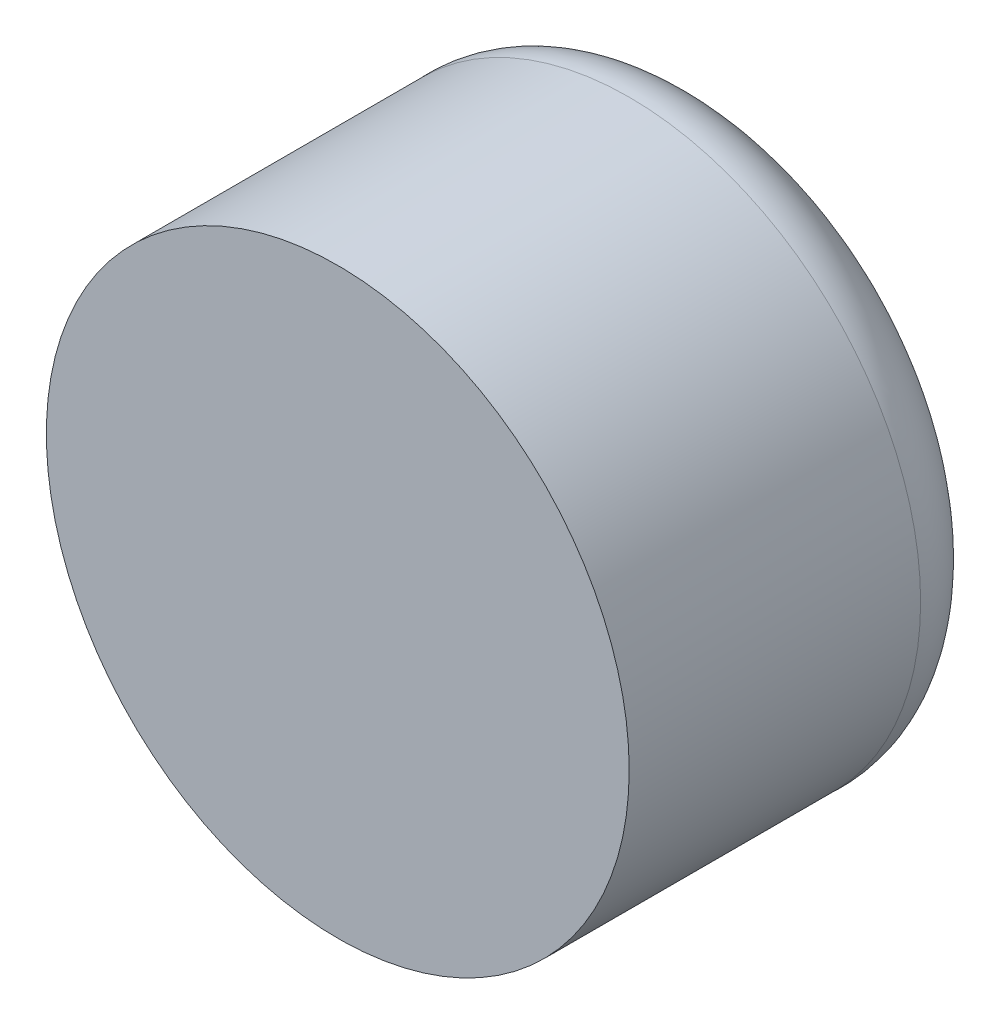
from build123d import *

# Parameters (mm, degrees)
SKETCH1_R           = 250
BOSS_EXTRUDE1_DEPTH = 250


with BuildPart() as part:
    # Sketch1 → Boss-Extrude1 (new body)
    with BuildSketch(Plane.XY):
        Circle(SKETCH1_R)
    extrude(amount=BOSS_EXTRUDE1_DEPTH)

    # Sketch2 → Revolve1 (revolve)
    with BuildSketch(Plane(origin=(0, 0, 0), x_dir=(0, 0, -1), z_dir=(1, 0, 0))):
        with BuildLine():
            Line((0, 0), (100, 0))
            add(Edge.make_bspline(
                [(0, 250), (99.714271477, 257.417440465), (98.757119487, 27.638299158), (100, 0)],
                knots=[0, 0, 0, 0, 1, 1, 1, 1], degree=3))
            Line((0, 250), (0, 0))
        make_face()
    revolve(axis=Axis((0, 0, 0), (0, 0, -1)))


solid = part.part
